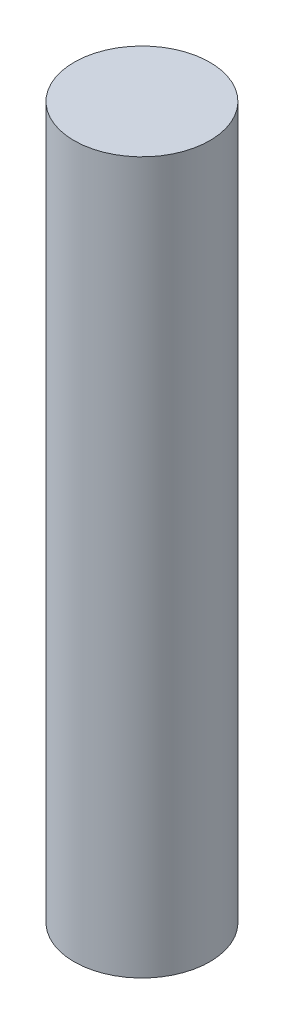
from build123d import *

# Parameters (mm, degrees)
SKETCH1_R           = 21
BOSS_EXTRUDE1_DEPTH = 220


with BuildPart() as part:
    # Sketch1 → Boss-Extrude1 (new body)
    with BuildSketch(Plane(origin=(0, 0, 0), x_dir=(1, 0, 0), z_dir=(0, 1, 0))):
        Circle(SKETCH1_R)
    extrude(amount=BOSS_EXTRUDE1_DEPTH)


solid = part.part
